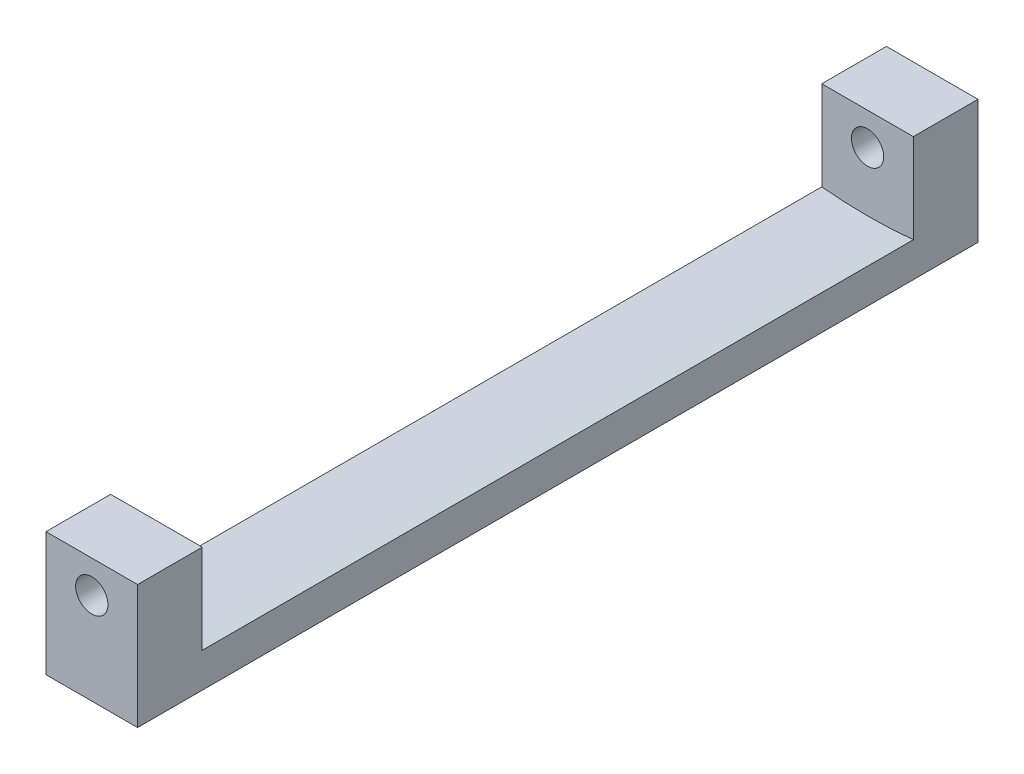
from build123d import *

# Parameters (mm, degrees)
BOSS_EXTRUDE1_DEPTH = 78
SKETCH2_W           = 8.5
SKETCH2_H           = 6
BOSS_EXTRUDE2_DEPTH = 8.5
SKETCH3_R           = 1.5
CUT_EXTRUDE1_DEPTH  = 100


with BuildPart() as part:
    # Sketch1 → Boss-Extrude1 (new body)
    with BuildSketch(Plane.XY):
        with BuildLine():
            Line((-4.25, -45.5), (4.25, -45.5))
            Line((4.25, -45.5), (4.25, -42.286966077))
            ThreePointArc((4.25, -42.286966077), (0, -42.5), (-4.25, -42.286966077))
            Line((-4.25, -42.286966077), (-4.25, -45.5))
        make_face()
    extrude(amount=BOSS_EXTRUDE1_DEPTH)

    # Sketch2 → Boss-Extrude2 (add)
    with BuildSketch(Plane(origin=(0, -42.5, 0), x_dir=(-1, 0, 0), z_dir=(0, -1, 0))):
        with Locations((0, -75)):
            Rectangle(SKETCH2_W, SKETCH2_H)
        with Locations((0, -3)):
            Rectangle(SKETCH2_W, SKETCH2_H)
    extrude(amount=-BOSS_EXTRUDE2_DEPTH)

    # Sketch3 → Cut-Extrude1 (cut)
    with BuildSketch(Plane(origin=(0, 0, 0), x_dir=(-1, 0, 0), z_dir=(0, 0, -1))):
        with Locations((0, -37)):
            Circle(SKETCH3_R)
    extrude(amount=-CUT_EXTRUDE1_DEPTH, mode=Mode.SUBTRACT)


solid = part.part
